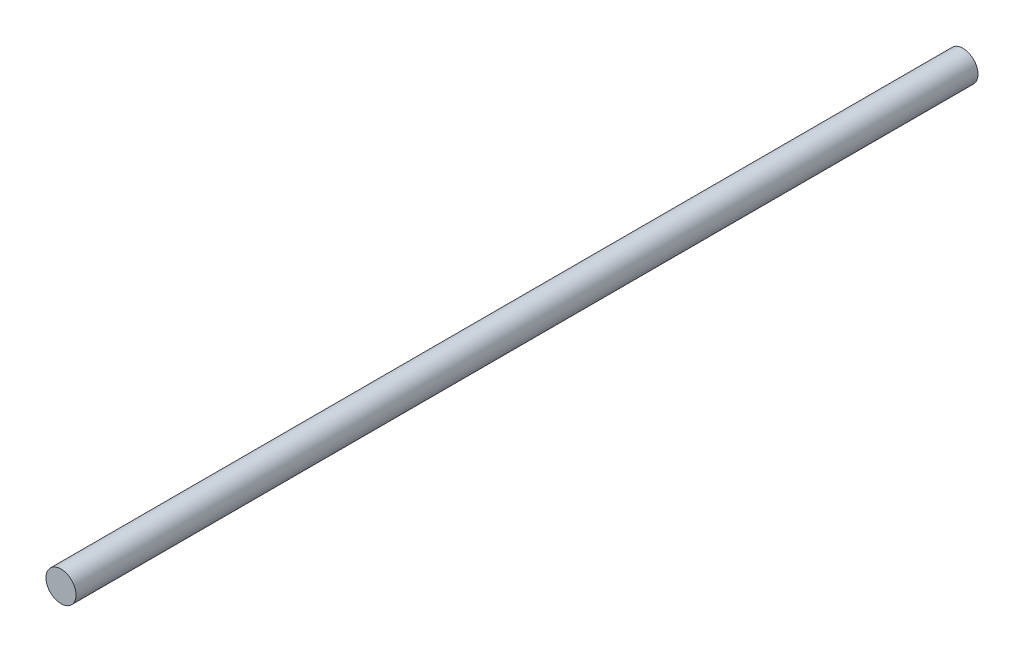
from build123d import *

# Parameters (mm, degrees)
SKETCH1_R           = 2
BOSS_EXTRUDE1_DEPTH = 120


with BuildPart() as part:
    # Sketch1 → Boss-Extrude1 (new body)
    with BuildSketch(Plane.XY):
        Circle(SKETCH1_R)
    extrude(amount=BOSS_EXTRUDE1_DEPTH)


solid = part.part
